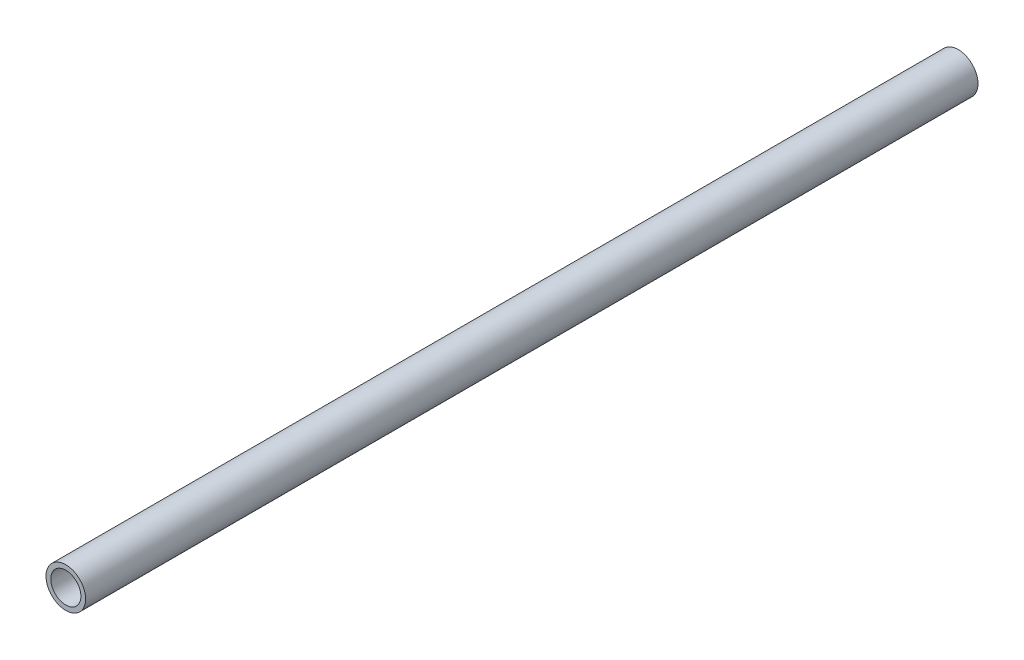
from build123d import *

# Parameters (mm, degrees)
SZKIC1_R                         = 8.35
SZKIC1_R_2                       = 6.35
DODANIE_WYCI_GNI_CIE1_DEPTH      = 374.716848
DODANIE_WYCI_GNI_CIE1_DEPTH_BACK = 1.218382


with BuildPart() as part:
    # Szkic1 → Dodanie-wyciągnięcie1 (new body, two sides)
    with BuildSketch(Plane.XY) as dodanie_wyci_gni_cie1_sk:
        Circle(SZKIC1_R)
        Circle(SZKIC1_R_2, mode=Mode.SUBTRACT)
    extrude(amount=DODANIE_WYCI_GNI_CIE1_DEPTH)
    extrude(dodanie_wyci_gni_cie1_sk.sketch, amount=-DODANIE_WYCI_GNI_CIE1_DEPTH_BACK)


solid = part.part
